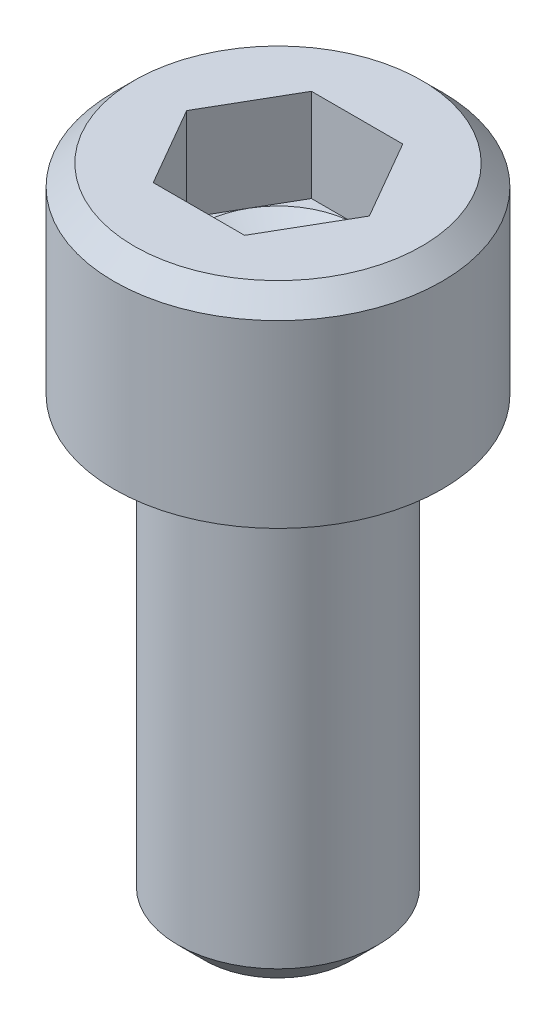
from build123d import *

# Parameters (mm, degrees)
SKETCH1_W           = 2.8702
SKETCH1_H           = 3.5052
SKETCH2_R           = 1.7526
BOSS_EXTRUDE1_DEPTH = 7.9375
CUT_EXTRUDE1_DEPTH  = 1.6256
CHAMFER1_SIZE       = 0.47244
CHAMFER2_SIZE       = 0.3556
FILLET1_R           = 0.254


with BuildPart() as part:
    # Sketch1 → Revolve1 (revolve)
    with BuildSketch(Plane.XY):
        with Locations((1.4351, 1.7526)):
            Rectangle(SKETCH1_W, SKETCH1_H)
    revolve(axis=Axis((0, 3.5052, 0), (0, -1, 0)))

    # Sketch2 → Boss-Extrude1 (add)
    with BuildSketch(Plane.XZ):
        Circle(SKETCH2_R)
    extrude(amount=BOSS_EXTRUDE1_DEPTH)

    # Sketch3 → Cut-Extrude1 (cut)
    with BuildSketch(Plane(origin=(0, 3.5052, 0), x_dir=(-1, 0, 0), z_dir=(0, 1, 0))):
        Polygon((-0.799225978, 1.3843), (-1.598451955, 0), (-0.799225978, -1.3843), (0.799225978, -1.3843), (1.598451955, 0), (0.799225978, 1.3843), align=None)
    extrude(amount=-CUT_EXTRUDE1_DEPTH, mode=Mode.SUBTRACT)

    # Sketch4 → Cut-Revolve1 (revolve, cut)
    with BuildSketch(Plane.XY):
        Polygon((1.3843, 1.8796), (0, 1.8796), (0, 1.080374022), align=None)
    revolve(axis=Axis((0, 1.879625, 0), (0, -1, 0)), mode=Mode.SUBTRACT)

    # Chamfer1
    chamfer1_edges = [part.edges().sort_by_distance(p)[0] for p in [
        (-1.7526, -7.9375, 0),
    ]]
    chamfer(chamfer1_edges, length=CHAMFER1_SIZE)

    # Chamfer2
    chamfer2_edges = [part.edges().sort_by_distance(p)[0] for p in [
        (-2.8702, 3.5052, 0),
    ]]
    chamfer(chamfer2_edges, length=CHAMFER2_SIZE)

    # Fillet1
    fillet1_edges = [part.edges().sort_by_distance(p)[0] for p in [
        (-1.7526, 0, 0),
    ]]
    fillet(fillet1_edges, radius=FILLET1_R)


solid = part.part
